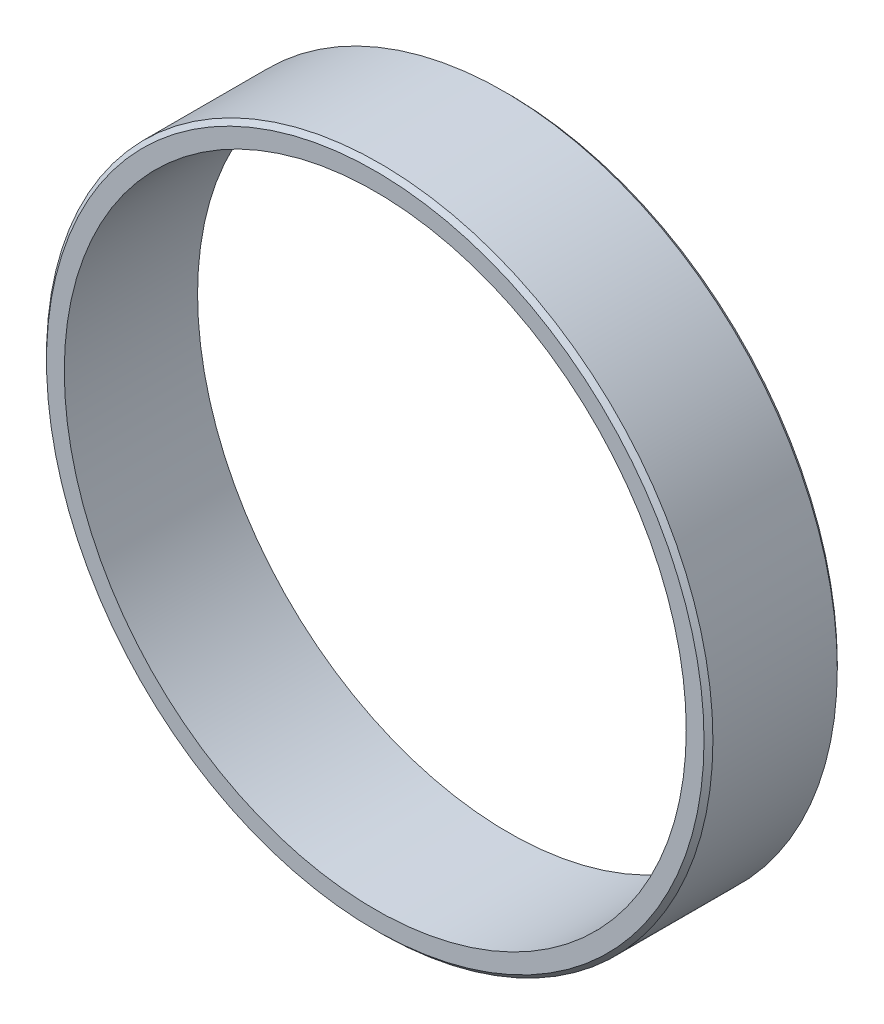
from build123d import *

# Parameters (mm, degrees)
SKETCH1_R           = 37.5
SKETCH1_R_2         = 35
BOSS_EXTRUDE1_DEPTH = 7.5
CHAMFER1_SIZE       = 0.5


with BuildPart() as part:
    # Sketch1 → Boss-Extrude1 (new body, symmetric)
    with BuildSketch(Plane.XY):
        Circle(SKETCH1_R)
        Circle(SKETCH1_R_2, mode=Mode.SUBTRACT)
    extrude(amount=BOSS_EXTRUDE1_DEPTH, both=True)

    # Chamfer1
    chamfer1_edges = [part.edges().sort_by_distance(p)[0] for p in [
        (-37.5, 0, -7.5),
        (-37.5, 0, 7.5),
    ]]
    chamfer(chamfer1_edges, length=CHAMFER1_SIZE)


solid = part.part
